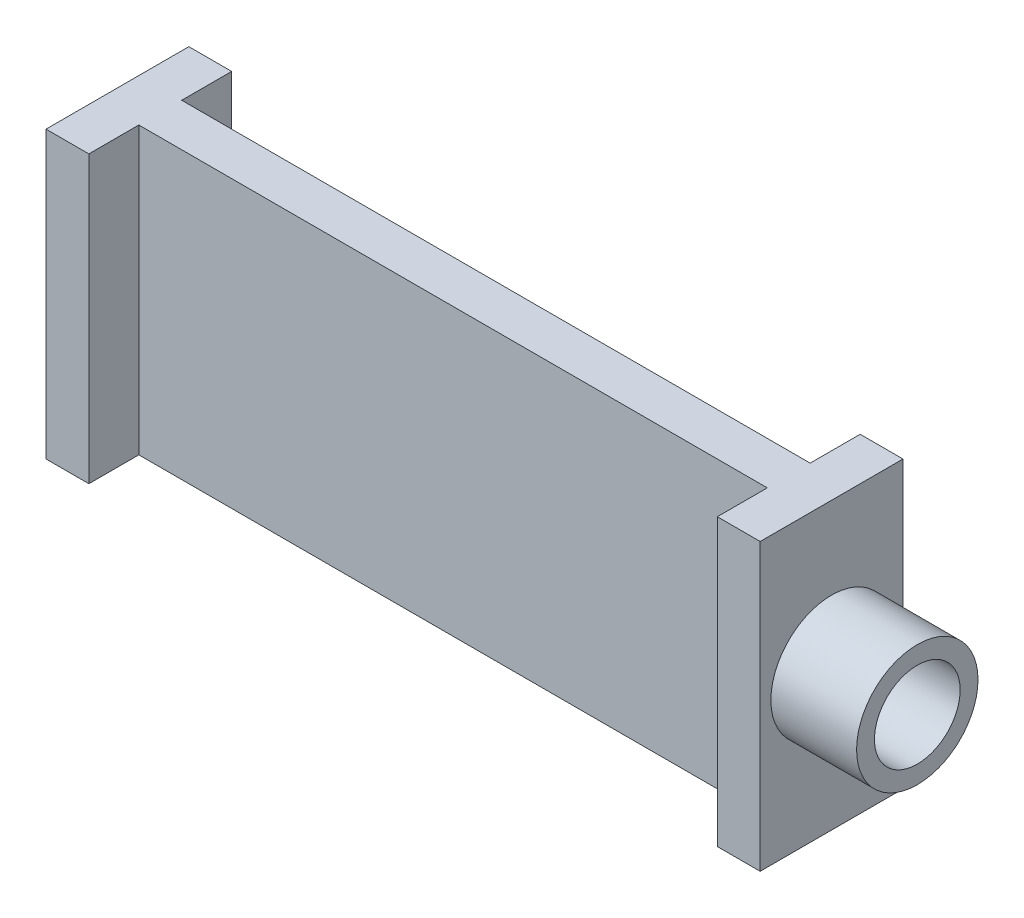
from build123d import *

# Parameters (mm, degrees)
BODY_DEPTH   = 40
SKETCH2_R    = 8.5
SKETCH2_R_2  = 6
NOZZLE_DEPTH = 12


with BuildPart() as part:
    # Sketch1 → Body (new body)
    with BuildSketch(Plane(origin=(0, 0, 0), x_dir=(1, 0, 0), z_dir=(0, 1, 0))):
        Polygon((0, 0), (0, 20), (6, 20), (6, 13), (94, 13), (94, 20), (100, 20), (100, 0), (94, 0), (94, 7), (6, 7), (6, 0), align=None)
    extrude(amount=BODY_DEPTH)

    # Sketch2 → Nozzle (add)
    with BuildSketch(Plane(origin=(100, 0, 0), x_dir=(0, 0, -1), z_dir=(1, 0, 0))):
        with Locations((10, 20)):
            Circle(SKETCH2_R)
        with Locations((10, 20)):
            Circle(SKETCH2_R_2, mode=Mode.SUBTRACT)
    extrude(amount=NOZZLE_DEPTH)


solid = part.part
